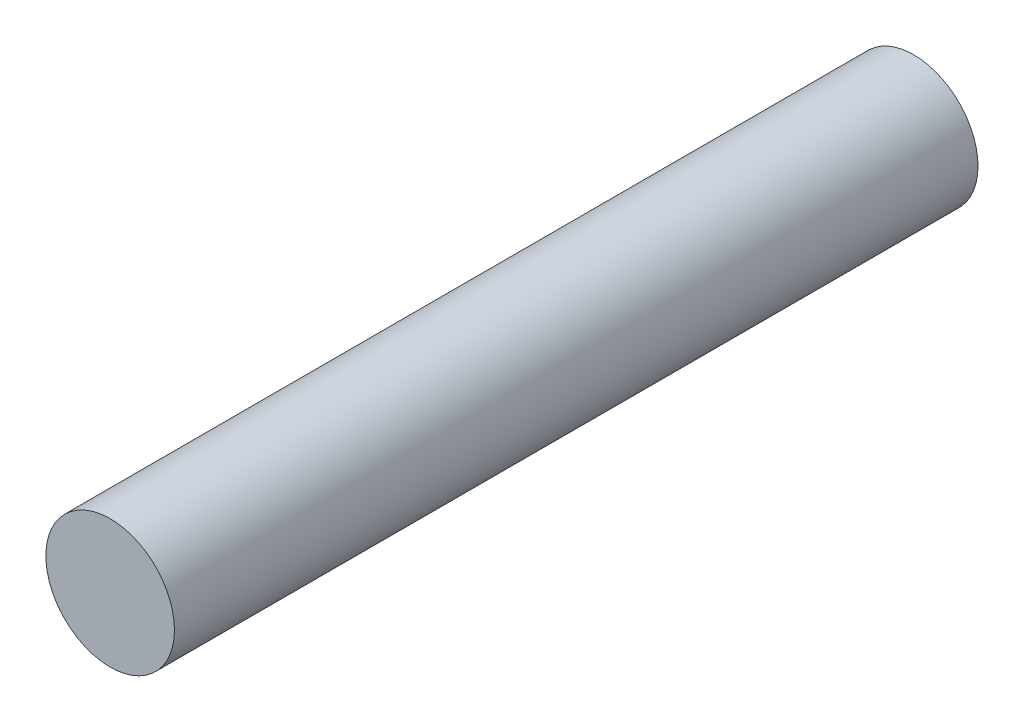
from build123d import *

# Parameters (mm, degrees)
ESBO_O1_R                = 4
RESSALTO_EXTRUS_O1_DEPTH = 50


with BuildPart() as part:
    # Esboço1 → Ressalto-extrusão1 (new body)
    with BuildSketch(Plane.XY):
        Circle(ESBO_O1_R)
    extrude(amount=RESSALTO_EXTRUS_O1_DEPTH)


solid = part.part
